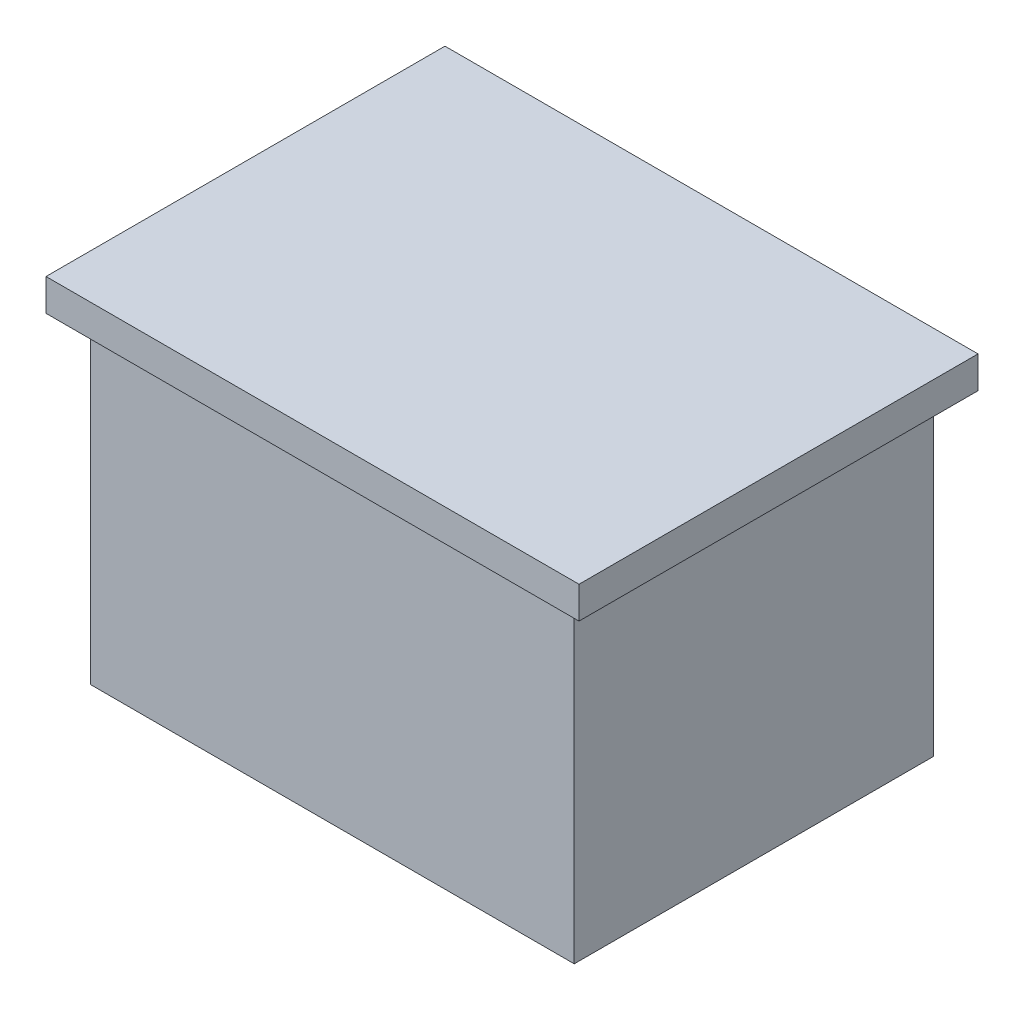
from build123d import *

# Parameters (mm, degrees)
SKETCH1_W           = 30.3
SKETCH1_H           = 22.5
BOSS_EXTRUDE1_DEPTH = 20
SKETCH2_W           = 33.4
SKETCH2_H           = 25
BOSS_EXTRUDE2_DEPTH = 2


with BuildPart() as part:
    # Sketch1 → Boss-Extrude1 (new body)
    with BuildSketch(Plane(origin=(0, 0, 0), x_dir=(1, 0, 0), z_dir=(0, 1, 0))):
        Rectangle(SKETCH1_W, SKETCH1_H)
    extrude(amount=BOSS_EXTRUDE1_DEPTH)

    # Sketch2 → Boss-Extrude2 (add)
    with BuildSketch(Plane(origin=(0, 20, 0), x_dir=(1, 0, 0), z_dir=(0, 1, 0))):
        Rectangle(SKETCH2_W, SKETCH2_H)
    extrude(amount=BOSS_EXTRUDE2_DEPTH)


solid = part.part
